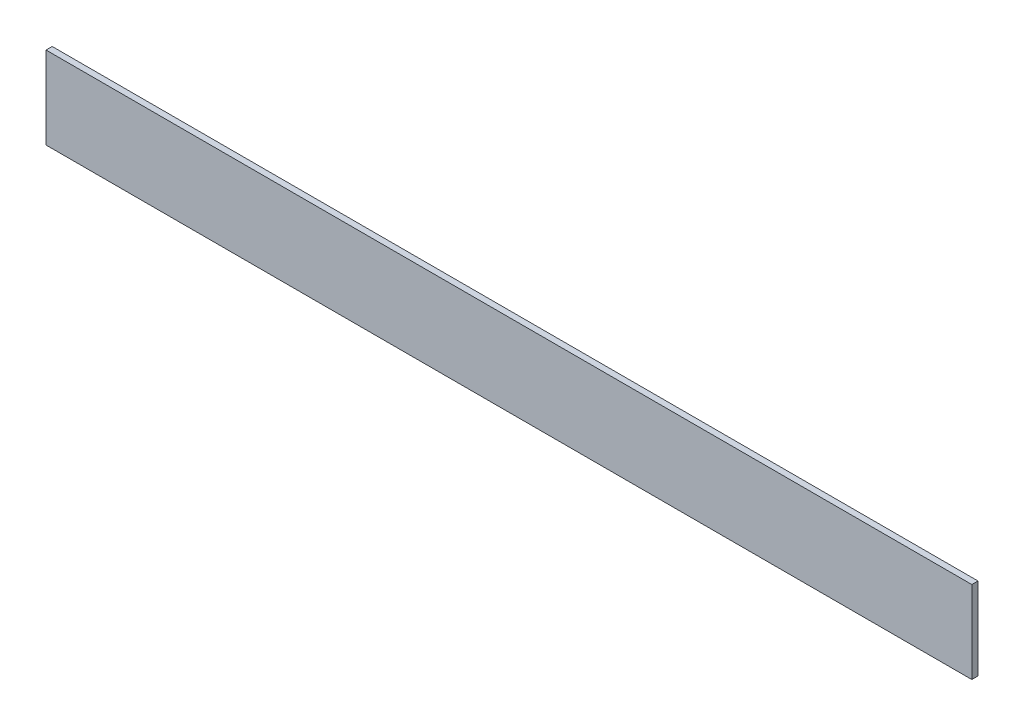
from build123d import *

# Parameters (mm, degrees)
SKETCH_1_W      = 450
SKETCH_1_H      = 40
EXTRUDE_1_DEPTH = 3


with BuildPart() as part:
    # 草图1 → 凸台-拉伸1 (new body)
    with BuildSketch(Plane.XY):
        with Locations((83.084451327, 60.225482395)):
            Rectangle(SKETCH_1_W, SKETCH_1_H)
    extrude(amount=EXTRUDE_1_DEPTH)


solid = part.part
